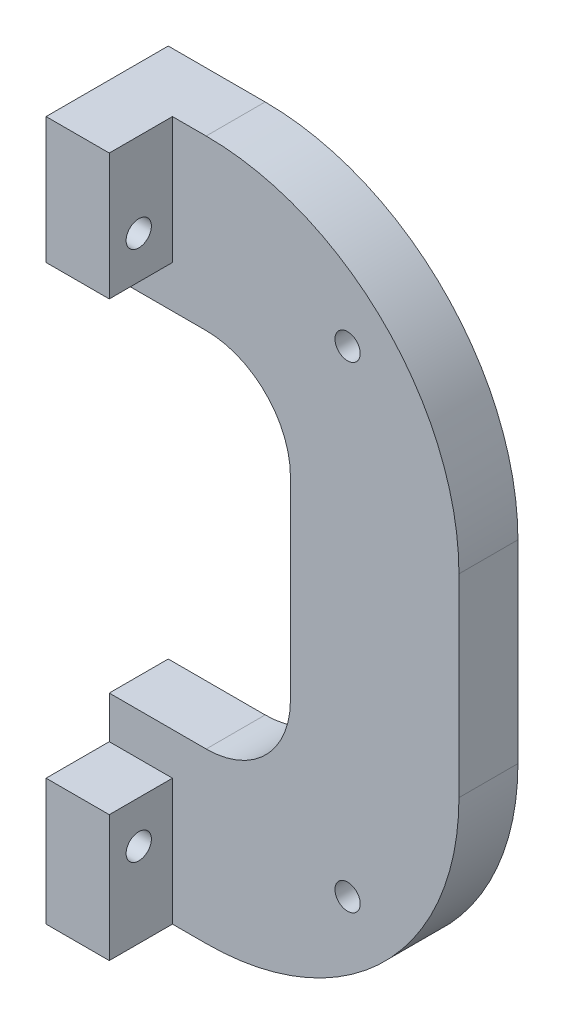
from build123d import *

# Parameters (mm, degrees)
BOSS_EXTRUDE4_DEPTH = 7
SKETCH6_W           = 7.5
SKETCH6_H           = 20
BOSS_EXTRUDE5_DEPTH = 7.5
SKETCH7_R           = 1.5
CUT_EXTRUDE3_DEPTH  = 7.5
SKETCH8_R           = 1.5
CUT_EXTRUDE4_DEPTH  = 7.5
SKETCH9_W           = 7.5
SKETCH9_H           = 5
CUT_EXTRUDE5_DEPTH  = 7.5


with BuildPart() as part:
    # Sketch1 → Boss-Extrude4 (new body)
    with BuildSketch(Plane.XY):
        with BuildLine():
            Line((41.5, -11.5), (41.5, 11.5))
            ThreePointArc((41.5, 11.5), (32.713203436, 32.713203436), (11.5, 41.5))
            Line((11.5, 41.5), (0, 41.5))
            Line((0, 41.5), (0, 21.5))
            Line((0, 21.5), (11.5, 21.5))
            ThreePointArc((11.5, 21.5), (18.571067812, 18.571067812), (21.5, 11.5))
            Line((21.5, 11.5), (21.5, -11.5))
            ThreePointArc((21.5, -11.5), (18.571067812, -18.571067812), (11.5, -21.5))
            Line((11.5, -21.5), (0, -21.5))
            Line((0, -21.5), (0, -41.5))
            Line((0, -41.5), (11.5, -41.5))
            ThreePointArc((11.5, -41.5), (32.713203436, -32.713203436), (41.5, -11.5))
        make_face()
    extrude(amount=BOSS_EXTRUDE4_DEPTH)

    # Sketch6 → Boss-Extrude5 (add)
    with BuildSketch(Plane.XY.offset(7)):
        with Locations((3.75, 31.5)):
            Rectangle(SKETCH6_W, SKETCH6_H)
        with Locations((3.75, -31.5)):
            Rectangle(SKETCH6_W, SKETCH6_H)
    extrude(amount=BOSS_EXTRUDE5_DEPTH)

    # Sketch7 → Cut-Extrude3 (cut)
    with BuildSketch(Plane(origin=(7.5, 0, 0), x_dir=(0, 0, -1), z_dir=(1, 0, 0))):
        with Locations((-11, 31.5)):
            Circle(SKETCH7_R)
        with Locations((-11, -31.5)):
            Circle(SKETCH7_R)
    extrude(amount=-CUT_EXTRUDE3_DEPTH, mode=Mode.SUBTRACT)

    # Sketch8 → Cut-Extrude4 (cut)
    with BuildSketch(Plane.XY.offset(7)):
        with Locations((28.284271247, 28.284271247)):
            Circle(SKETCH8_R)
        with Locations((28.284271247, -28.284271247)):
            Circle(SKETCH8_R)
    extrude(amount=-CUT_EXTRUDE4_DEPTH, mode=Mode.SUBTRACT)

    # Sketch9 → Cut-Extrude5 (cut)
    with BuildSketch(Plane(origin=(7.5, 0, 0), x_dir=(0, 0, -1), z_dir=(1, 0, 0))):
        with Locations((-10.75, 24)):
            Rectangle(SKETCH9_W, SKETCH9_H)
        with Locations((-10.75, -24)):
            Rectangle(SKETCH9_W, SKETCH9_H)
    extrude(amount=-CUT_EXTRUDE5_DEPTH, mode=Mode.SUBTRACT)


solid = part.part
